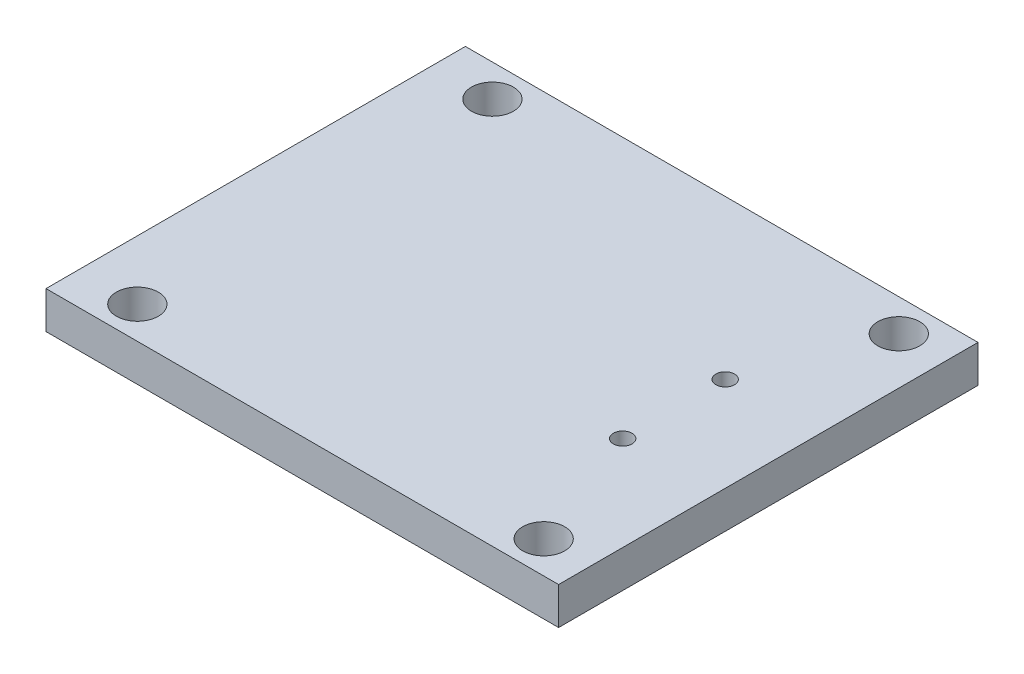
from build123d import *

# Parameters (mm, degrees)
SKETCH1_W           = 22
SKETCH1_H           = 18
BOSS_EXTRUDE2_DEPTH = 1.6
SKETCH4_R           = 0.9
CUT_EXTRUDE5_DEPTH  = 1.6
SKETCH9_R           = 0.4
CUT_EXTRUDE6_DEPTH  = 10


with BuildPart() as part:
    # Sketch1 → Boss-Extrude2 (new body)
    with BuildSketch(Plane(origin=(0, 0, 0), x_dir=(1, 0, 0), z_dir=(0, 1, 0))):
        with Locations((17.78, 7.62)):
            Rectangle(SKETCH1_W, SKETCH1_H)
    extrude(amount=BOSS_EXTRUDE2_DEPTH)

    # Sketch4 → Cut-Extrude5 (cut)
    with BuildSketch(Plane(origin=(0, 0, 0), x_dir=(1, 0, 0), z_dir=(0, 1, 0))):
        with Locations((26.76, 15.24)):
            Circle(SKETCH4_R)
        with Locations((26.76, 0)):
            Circle(SKETCH4_R)
        with Locations((9.32, 0)):
            Circle(SKETCH4_R)
        with Locations((9.32, 15.24)):
            Circle(SKETCH4_R)
    extrude(amount=CUT_EXTRUDE5_DEPTH, mode=Mode.SUBTRACT)

    # Sketch9 → Cut-Extrude6 (cut)
    with BuildSketch(Plane(origin=(0, 0, 0), x_dir=(1, 0, 0), z_dir=(0, 1, 0))):
        with Locations((24.73, 5.42)):
            Circle(SKETCH9_R)
        with Locations((24.73, 9.82)):
            Circle(SKETCH9_R)
    extrude(amount=CUT_EXTRUDE6_DEPTH, mode=Mode.SUBTRACT)


solid = part.part
